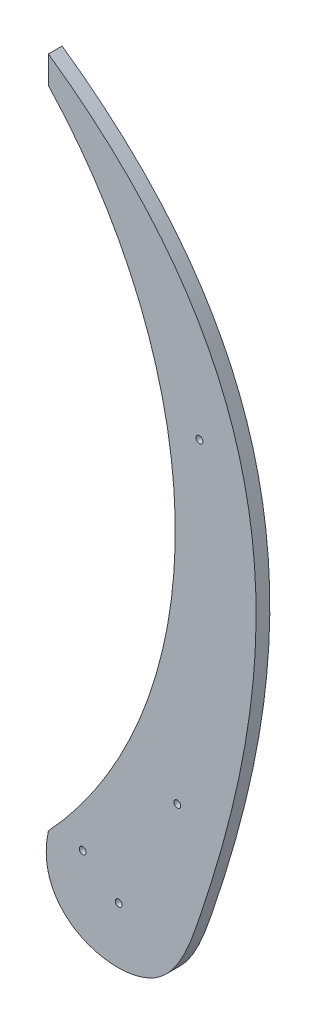
from build123d import *

# Parameters (mm, degrees)
SKETCH2_R           = 2.5
BOSS_EXTRUDE1_DEPTH = 10


with BuildPart() as part:
    # Sketch2 → Boss-Extrude1 (new body)
    with BuildSketch(Plane.XY):
        with BuildLine():
            Line((0, 490), (0, 470))
            ThreePointArc((0, 470), (92.413381194, 235), (0, 0))
            add(Edge.make_bspline(
                [(0, 0), (-11.951204199, -54.546265489), (80.548673529, -82.159808708), (170.986519024, 164.604032126), (184.128749578, 361.075064975), (0, 490)],
                knots=[0, 0, 0, 0, 0.154451472, 0.243976965, 1, 1, 1, 1], degree=3))
        make_face()
        with Locations((25, 0)):
            Circle(SKETCH2_R, mode=Mode.SUBTRACT)
        with Locations((51.23475383, -20)):
            Circle(SKETCH2_R, mode=Mode.SUBTRACT)
        with Locations((93.897163584, 63.808979888)):
            Circle(SKETCH2_R, mode=Mode.SUBTRACT)
        with Locations((110, 301.715955406)):
            Circle(SKETCH2_R, mode=Mode.SUBTRACT)
    extrude(amount=BOSS_EXTRUDE1_DEPTH)


solid = part.part
